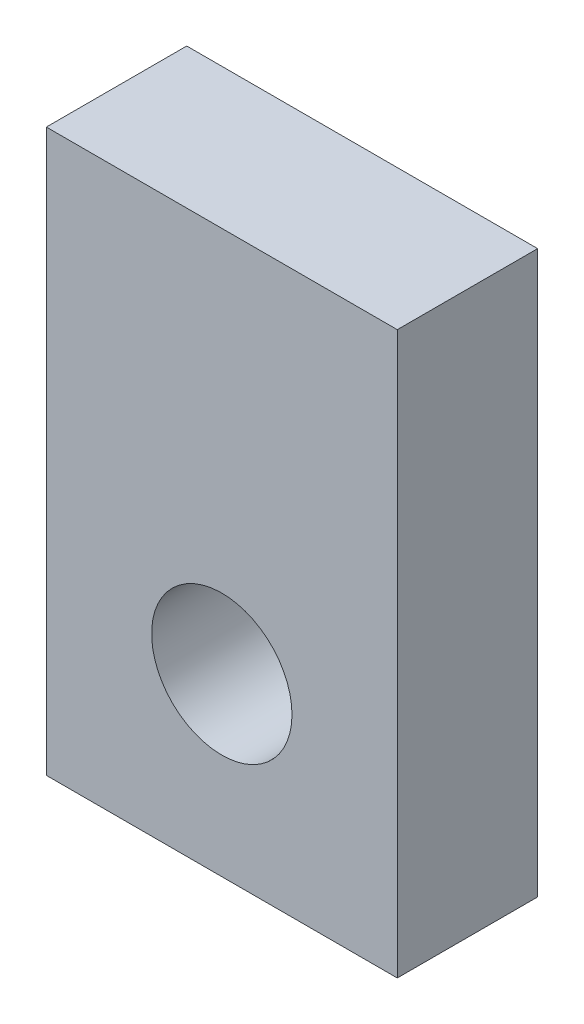
from build123d import *

# Parameters (mm, degrees)
SKETCH1_W           = 10
SKETCH1_H           = 4
BOSS_EXTRUDE1_DEPTH = 16
SKETCH2_R           = 2
CUT_EXTRUDE1_DEPTH  = 5


with BuildPart() as part:
    # Sketch1 → Boss-Extrude1 (new body)
    with BuildSketch(Plane(origin=(0, 0, 0), x_dir=(1, 0, 0), z_dir=(0, 1, 0))):
        with Locations((-5, 2)):
            Rectangle(SKETCH1_W, SKETCH1_H)
    extrude(amount=BOSS_EXTRUDE1_DEPTH)

    # Sketch2 → Cut-Extrude1 (cut, through all)
    with BuildSketch(Plane.XY):
        with Locations((-5, 5)):
            Circle(SKETCH2_R)
    extrude(amount=-CUT_EXTRUDE1_DEPTH, mode=Mode.SUBTRACT)


solid = part.part
